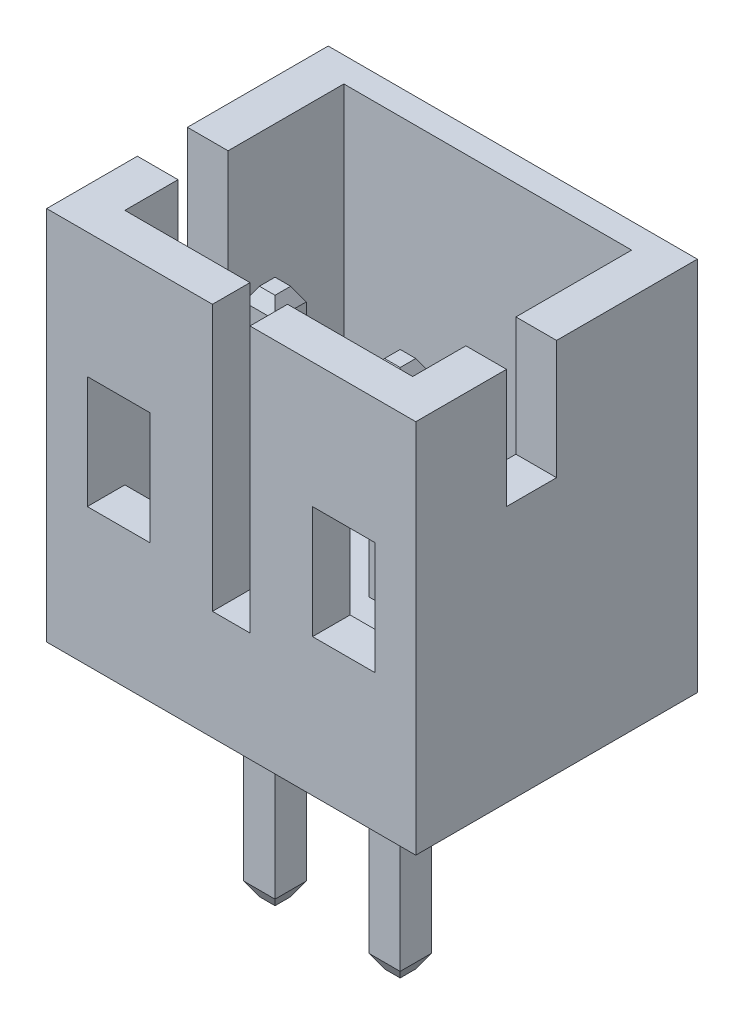
from build123d import *

# Parameters (mm, degrees)
SKETCH1_W            = 6
SKETCH1_H            = 4.1
BOSS_EXTRUDE1_DEPTH  = 2.6
SKETCH2_W            = 2.6
SKETCH2_H            = 3.5
CUT_EXTRUDE1_DEPTH   = 4.25
SKETCH3_W            = 0.6
SKETCH3_H            = 4.25
CUT_EXTRUDE2_DEPTH   = 1.6
SKETCH4_W            = 1
SKETCH4_H            = 0.6
BOSS_EXTRUDE2_DEPTH  = 4.25
BOSS_EXTRUDE3_DEPTH  = 1
SKETCH6_W            = 0.6
SKETCH6_H            = 2
BOSS_EXTRUDE4_DEPTH  = 1
SKETCH7_W            = 4.1
SKETCH7_H            = 6
BOSS_EXTRUDE5_DEPTH  = 0.65
SKETCH8_W            = 0.6
SKETCH8_H            = 2
BOSS_EXTRUDE6_DEPTH  = 1
BOSS_EXTRUDE7_DEPTH  = 1
SKETCH10_W           = 4.1
SKETCH10_H           = 6
BOSS_EXTRUDE8_DEPTH  = 0.65
SKETCH11_W           = 5.9
SKETCH11_H           = 6
BOSS_EXTRUDE9_DEPTH  = 0.4
SKETCH12_W           = 0.8
SKETCH12_H           = 1.9
CUT_EXTRUDE3_DEPTH   = 1.65
SKETCH13_W           = 0.8
SKETCH13_H           = 1.9
CUT_EXTRUDE4_DEPTH   = 6.9
SKETCH14_W           = 0.5
SKETCH14_H           = 0.5
BOSS_EXTRUDE10_DEPTH = 3.3
SKETCH15_W           = 0.5
SKETCH15_H           = 0.5
BOSS_EXTRUDE11_DEPTH = 3.3
SKETCH16_W           = 0.5
SKETCH16_H           = 0.5
BOSS_EXTRUDE12_DEPTH = 3.4
SKETCH17_W           = 0.5
SKETCH17_H           = 0.5
BOSS_EXTRUDE13_DEPTH = 3.4
CHAMFER1_SIZE        = 0.125
CHAMFER1_SIZE2       = 0.216506351
CHAMFER2_SIZE        = 0.125
CHAMFER2_SIZE2       = 0.216506351
CHAMFER3_SIZE        = 0.125
CHAMFER3_SIZE2       = 0.216506351
CHAMFER4_SIZE        = 0.125
CHAMFER4_SIZE2       = 0.216506351


with BuildPart() as part:
    # Sketch1 → Boss-Extrude1 (new body)
    with BuildSketch(Plane(origin=(4.6, 0, 0), x_dir=(0, -1, 0), z_dir=(-1, 0, 0))):
        with Locations((-3, 2.45)):
            Rectangle(SKETCH1_W, SKETCH1_H)
    extrude(amount=-BOSS_EXTRUDE1_DEPTH)

    # Sketch2 → Cut-Extrude1 (cut)
    with BuildSketch(Plane(origin=(0, 6, 0), x_dir=(-1, 0, 0), z_dir=(0, 1, 0))):
        with Locations((-5.9, 2.15)):
            Rectangle(SKETCH2_W, SKETCH2_H)
    extrude(amount=-CUT_EXTRUDE1_DEPTH, mode=Mode.SUBTRACT)

    # Sketch3 → Cut-Extrude2 (cut)
    with BuildSketch(Plane.ZY.offset(-4.6)):
        with Locations((4.2, 3.875)):
            Rectangle(SKETCH3_W, SKETCH3_H)
    extrude(amount=-CUT_EXTRUDE2_DEPTH, mode=Mode.SUBTRACT)

    # Sketch4 → Boss-Extrude2 (add)
    with BuildSketch(Plane(origin=(0, 1.75, 0), x_dir=(-1, 0, 0), z_dir=(0, 1, 0))):
        with Locations((-5.1, 4.2)):
            Rectangle(SKETCH4_W, SKETCH4_H)
    extrude(amount=BOSS_EXTRUDE2_DEPTH)

    # Sketch5 → Boss-Extrude3 (add)
    with BuildSketch(Plane.ZY.offset(-4.6)):
        Polygon((0.4, 0), (0.4, 1.75), (3.9, 1.75), (3.9, 2.2), (4.5, 2.2), (4.5, 0), align=None)
    extrude(amount=BOSS_EXTRUDE3_DEPTH)

    # Sketch6 → Boss-Extrude4 (add)
    with BuildSketch(Plane.ZY.offset(-4.6)):
        with Locations((4.2, 5)):
            Rectangle(SKETCH6_W, SKETCH6_H)
    extrude(amount=BOSS_EXTRUDE4_DEPTH)

    # Sketch7 → Boss-Extrude5 (add)
    with BuildSketch(Plane.ZY.offset(-3.6)):
        with Locations((2.45, 3)):
            Rectangle(SKETCH7_W, SKETCH7_H)
    extrude(amount=BOSS_EXTRUDE5_DEPTH)

    # Sketch8 → Boss-Extrude6 (add)
    with BuildSketch(Plane(origin=(7.2, 0, 0), x_dir=(0, 0, -1), z_dir=(1, 0, 0))):
        with Locations((-4.2, 5)):
            Rectangle(SKETCH8_W, SKETCH8_H)
    extrude(amount=BOSS_EXTRUDE6_DEPTH)

    # Sketch9 → Boss-Extrude7 (add)
    with BuildSketch(Plane(origin=(7.2, 0, 0), x_dir=(0, 0, -1), z_dir=(1, 0, 0))):
        Polygon((-3.9, 1.75), (-0.4, 1.75), (-0.4, 0), (-4.5, 0), (-4.5, 2.2), (-3.9, 2.2), align=None)
    extrude(amount=BOSS_EXTRUDE7_DEPTH)

    # Sketch10 → Boss-Extrude8 (add)
    with BuildSketch(Plane(origin=(8.2, 0, 0), x_dir=(0, 0, -1), z_dir=(1, 0, 0))):
        with Locations((-2.45, 3)):
            Rectangle(SKETCH10_W, SKETCH10_H)
    extrude(amount=BOSS_EXTRUDE8_DEPTH)

    # Sketch11 → Boss-Extrude9 (add)
    with BuildSketch(Plane(origin=(0, 0, 0.4), x_dir=(-1, 0, 0), z_dir=(0, 0, -1))):
        with Locations((-5.9, 3)):
            Rectangle(SKETCH11_W, SKETCH11_H)
    extrude(amount=BOSS_EXTRUDE9_DEPTH)

    # Sketch12 → Cut-Extrude3 (cut, through all)
    with BuildSketch(Plane(origin=(3.6, 0, 0), x_dir=(0, 0, -1), z_dir=(1, 0, 0))):
        with Locations((-2.65, 5.05)):
            Rectangle(SKETCH12_W, SKETCH12_H)
    extrude(amount=-CUT_EXTRUDE3_DEPTH, mode=Mode.SUBTRACT)

    # Sketch13 → Cut-Extrude4 (cut, through all)
    with BuildSketch(Plane(origin=(8.85, 0, 0), x_dir=(0, 0, -1), z_dir=(1, 0, 0))):
        with Locations((-2.65, 5.05)):
            Rectangle(SKETCH13_W, SKETCH13_H)
    extrude(amount=-CUT_EXTRUDE4_DEPTH, mode=Mode.SUBTRACT)


with BuildPart() as body_2:
    # Sketch14 → Boss-Extrude10 (new body)
    with BuildSketch(Plane(origin=(0, 1.75, 0), x_dir=(-1, 0, 0), z_dir=(0, 1, 0))):
        with Locations((-4.9, 2.8)):
            Rectangle(SKETCH14_W, SKETCH14_H)
    extrude(amount=BOSS_EXTRUDE10_DEPTH)

    # Chamfer1
    chamfer1_edges = [body_2.edges().sort_by_distance(p)[0] for p in [
        (5.15, 5.05, 2.8),
        (4.9, 5.05, 2.55),
        (4.65, 5.05, 2.8),
        (4.9, 5.05, 3.05),
    ]]
    chamfer1_side = [body_2.faces().sort_by_distance(p)[0] for p in [
        (4.9, 5.05, 2.8),
    ]]
    chamfer(chamfer1_edges, length=CHAMFER1_SIZE, length2=CHAMFER1_SIZE2, reference=chamfer1_side[0])


with BuildPart() as body_3:
    # Sketch15 → Boss-Extrude11 (new body)
    with BuildSketch(Plane(origin=(0, 1.75, 0), x_dir=(-1, 0, 0), z_dir=(0, 1, 0))):
        with Locations((-6.9, 2.8)):
            Rectangle(SKETCH15_W, SKETCH15_H)
    extrude(amount=BOSS_EXTRUDE11_DEPTH)

    # Chamfer2
    chamfer2_edges = [body_3.edges().sort_by_distance(p)[0] for p in [
        (7.15, 5.05, 2.8),
        (6.9, 5.05, 2.55),
        (6.65, 5.05, 2.8),
        (6.9, 5.05, 3.05),
    ]]
    chamfer2_side = [body_3.faces().sort_by_distance(p)[0] for p in [
        (6.9, 5.05, 2.8),
    ]]
    chamfer(chamfer2_edges, length=CHAMFER2_SIZE, length2=CHAMFER2_SIZE2, reference=chamfer2_side[0])


with BuildPart() as body_4:
    # Sketch16 → Boss-Extrude12 (new body)
    with BuildSketch(Plane.XZ):
        with Locations((4.9, 2.8)):
            Rectangle(SKETCH16_W, SKETCH16_H)
    extrude(amount=BOSS_EXTRUDE12_DEPTH)

    # Chamfer4
    chamfer4_edges = [body_4.edges().sort_by_distance(p)[0] for p in [
        (4.9, -3.4, 2.55),
        (5.15, -3.4, 2.8),
        (4.9, -3.4, 3.05),
        (4.65, -3.4, 2.8),
    ]]
    chamfer4_side = [body_4.faces().sort_by_distance(p)[0] for p in [
        (4.9, -3.4, 2.8),
    ]]
    chamfer(chamfer4_edges, length=CHAMFER4_SIZE, length2=CHAMFER4_SIZE2, reference=chamfer4_side[0])


with BuildPart() as body_5:
    # Sketch17 → Boss-Extrude13 (new body)
    with BuildSketch(Plane.XZ):
        with Locations((6.9, 2.8)):
            Rectangle(SKETCH17_W, SKETCH17_H)
    extrude(amount=BOSS_EXTRUDE13_DEPTH)

    # Chamfer3
    chamfer3_edges = [body_5.edges().sort_by_distance(p)[0] for p in [
        (6.9, -3.4, 2.55),
        (7.15, -3.4, 2.8),
        (6.9, -3.4, 3.05),
        (6.65, -3.4, 2.8),
    ]]
    chamfer3_side = [body_5.faces().sort_by_distance(p)[0] for p in [
        (6.9, -3.4, 2.8),
    ]]
    chamfer(chamfer3_edges, length=CHAMFER3_SIZE, length2=CHAMFER3_SIZE2, reference=chamfer3_side[0])


solid = Compound([part.part, body_2.part, body_3.part, body_4.part, body_5.part])
